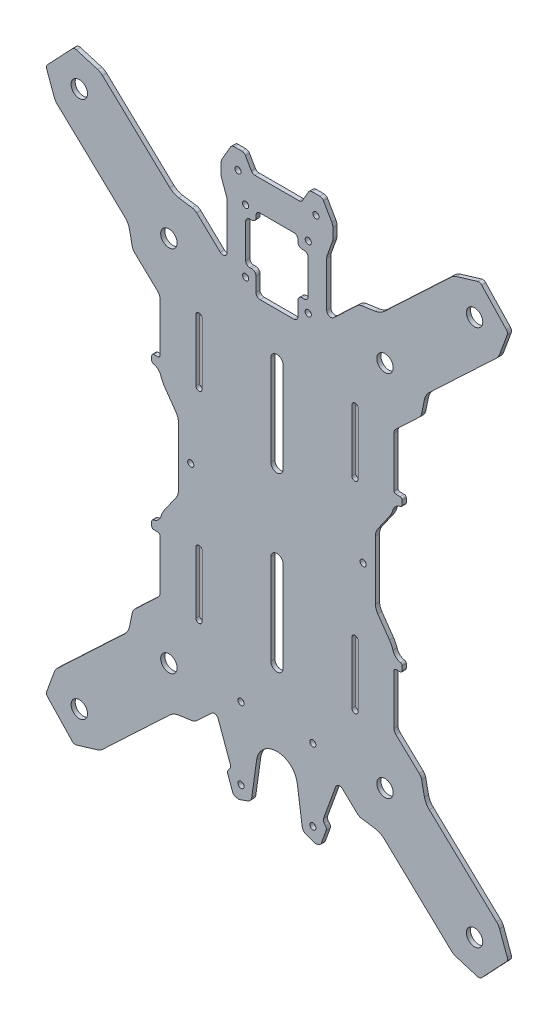
from build123d import *

# Parameters (mm, degrees)
MODEL_R             = 1.5
MODEL_R_2           = 4
BOSS_EXTRUDE1_DEPTH = 2


with BuildPart() as part:
    # Model → Boss-Extrude1 (new body)
    with BuildSketch(Plane.XY):
        with BuildLine():
            Line((200.412741898, 281.313149756), (207.019417582, 282.280309624))
            ThreePointArc((207.019417582, 282.280309624), (209.346062513, 282.995121659), (211.350075005, 284.376485771))
            Line((211.350075005, 284.376485771), (244.129053352, 315.296551711))
            ThreePointArc((244.129053352, 315.296551711), (245.241966673, 316.125703781), (246.515608428, 316.676980382))
            Line((246.515608428, 316.676980382), (256.822115777, 319.781518108))
            ThreePointArc((256.822115777, 319.781518108), (257.915045318, 319.798780278), (258.853822051, 319.238877422))
            Line((258.853822051, 319.238877422), (270.881078242, 306.488534933))
            ThreePointArc((270.881078242, 306.488534933), (271.385286838, 305.518706556), (271.304323373, 304.428643114))
            Line((271.304323373, 304.428643114), (267.604044674, 294.320716089))
            ThreePointArc((267.604044674, 294.320716089), (266.97943365, 293.081391094), (266.08679354, 292.018725103))
            Line((266.08679354, 292.018725103), (233.307822643, 261.098651713))
            ThreePointArc((233.307822643, 261.098651713), (231.811945064, 259.178604865), (230.962670444, 256.897604591))
            Line((230.962670444, 256.897604591), (229.611880181, 250.358572728))
            ThreePointArc((229.611880181, 250.358572728), (229.187245122, 249.218070958), (228.439307807, 248.258045441))
            Line((228.439307807, 248.258045441), (217.071655242, 237.535050637))
            ThreePointArc((217.071655242, 237.535050637), (216.375596078, 236.54111239), (216.130192427, 235.352756953))
            Line((216.130192427, 235.352756953), (216.130192427, 211.085992432))
            ThreePointArc((216.130192427, 211.085992432), (216.423085646, 210.378887349), (217.130190728, 210.085994131))
            Line((217.130190728, 210.085994131), (219.130191056, 210.085994131))
            ThreePointArc((219.130191056, 210.085994131), (219.837298547, 209.793102229), (220.130193083, 209.085995829))
            Line((220.130193083, 209.085995829), (220.130193083, 206.997061646))
            ThreePointArc((220.130193083, 206.997061646), (219.897158, 206.355372138), (219.306662985, 206.012755135))
            ThreePointArc((219.306662985, 206.012755135), (217.010488019, 204.889950302), (215.650192397, 202.725994205))
            ThreePointArc((215.650192397, 202.725994205), (214.949457219, 200.895279905), (213.960017113, 199.203076339))
            Line((213.960017113, 199.203076339), (208.215280471, 190.998742855))
            ThreePointArc((208.215280471, 190.998742855), (207.407891081, 189.361519051), (207.130192814, 187.557284287))
            Line((207.130192814, 187.557284287), (207.130192814, 158.688374361))
            ThreePointArc((207.130192814, 158.688374361), (207.407891081, 156.884139597), (208.215280471, 155.246915793))
            Line((208.215280471, 155.246915793), (213.960017113, 147.042582309))
            ThreePointArc((213.960017113, 147.042582309), (214.949457219, 145.350378743), (215.650192397, 143.519664444))
            ThreePointArc((215.650192397, 143.519664444), (217.010488019, 141.355708346), (219.306662985, 140.232903514))
            ThreePointArc((219.306662985, 140.232903514), (219.897158001, 139.89028651), (220.130193083, 139.248597002))
            Line((220.130193083, 139.248597002), (220.130193083, 137.159662819))
            ThreePointArc((220.130193083, 137.159662819), (219.837298547, 136.452556419), (219.130191056, 136.159664518))
            Line((219.130191056, 136.159664518), (217.130190728, 136.159664518))
            ThreePointArc((217.130190728, 136.159664518), (216.423085646, 135.866771299), (216.130192427, 135.159666216))
            Line((216.130192427, 135.159666216), (216.130192427, 110.892901695))
            ThreePointArc((216.130192427, 110.892901695), (216.375596078, 109.704546258), (217.071655242, 108.710608012))
            Line((217.071655242, 108.710608012), (228.439307807, 97.987613207))
            ThreePointArc((228.439307807, 97.987613207), (229.187245122, 97.02758769), (229.611880181, 95.887085921))
            Line((229.611880181, 95.887085921), (230.962670444, 89.348054058))
            ThreePointArc((230.962670444, 89.348054058), (231.811945064, 87.067053783), (233.307822643, 85.147006935))
            Line((233.307822643, 85.147006935), (266.08679354, 54.226933545))
            ThreePointArc((266.08679354, 54.226933545), (266.97943365, 53.164267554), (267.604044674, 51.924942559))
            Line((267.604044674, 51.924942559), (271.304323373, 41.817015535))
            ThreePointArc((271.304323373, 41.817015535), (271.385286838, 40.726952092), (270.881078242, 39.757123715))
            Line((270.881078242, 39.757123715), (258.853822051, 27.006781226))
            ThreePointArc((258.853822051, 27.006781226), (257.915045318, 26.44687837), (256.822115777, 26.464140541))
            Line((256.822115777, 26.464140541), (246.515608428, 29.568678266))
            ThreePointArc((246.515608428, 29.568678266), (245.241966673, 30.119954868), (244.129053352, 30.949106938))
            Line((244.129053352, 30.949106938), (211.350075005, 61.869172877))
            ThreePointArc((211.350075005, 61.869172877), (209.346062513, 63.25053699), (207.019417582, 63.965349025))
            Line((207.019417582, 63.965349025), (200.412741898, 64.932508892))
            ThreePointArc((200.412741898, 64.932508892), (199.24942012, 65.28991142), (198.247413186, 65.980589515))
            Line((198.247413186, 65.980589515), (191.012158094, 72.805537409))
            ThreePointArc((191.012158094, 72.805537409), (189.178482522, 73.296740969), (187.76041366, 72.034707791))
            Line((187.76041366, 72.034707791), (181.83126211, 55.744505054))
            ThreePointArc((181.83126211, 55.744505054), (181.741033127, 54.713169482), (182.178559748, 53.774891919))
            Line((182.178559748, 53.774891919), (182.735229878, 53.111477321))
            ThreePointArc((182.735229878, 53.111477321), (183.172757635, 52.173195972), (183.082525654, 51.141856736))
            Line((183.082525654, 51.141856736), (180.712941138, 44.631472355))
            ThreePointArc((180.712941138, 44.631472355), (180.11912963, 43.783427967), (179.180852173, 43.345904476))
            Line((179.180852173, 43.345904476), (177.86146052, 43.113252646))
            ThreePointArc((177.86146052, 43.113252646), (177.60065559, 43.101868291), (177.345790936, 43.158373362))
            Line((177.345790936, 43.158373362), (173.367758317, 44.606259591))
            ThreePointArc((173.367758317, 44.606259591), (172.062380787, 45.537377253), (171.42301522, 47.007820135))
            Line((171.42301522, 47.007820135), (169.03287269, 64.014560109))
            ThreePointArc((169.03287269, 64.014560109), (159.130192397, 72.622826292), (149.227512104, 64.014560109))
            Line((149.227512104, 64.014560109), (146.837369574, 47.007820135))
            ThreePointArc((146.837369574, 47.007820135), (146.198004008, 45.537377253), (144.892626477, 44.606259591))
            Line((144.892626477, 44.606259591), (140.914593859, 43.158373362))
            ThreePointArc((140.914593859, 43.158373362), (140.659729204, 43.101868291), (140.398924274, 43.113252646))
            Line((140.398924274, 43.113252646), (139.079532621, 43.345904476))
            ThreePointArc((139.079532621, 43.345904476), (138.141255164, 43.783427967), (137.547443656, 44.631472355))
            Line((137.547443656, 44.631472355), (135.177859141, 51.141856736))
            ThreePointArc((135.177859141, 51.141856736), (135.087627159, 52.173195972), (135.525154917, 53.111477321))
            Line((135.525154917, 53.111477321), (136.081825046, 53.774891919))
            ThreePointArc((136.081825046, 53.774891919), (136.519351668, 54.713169482), (136.429122685, 55.744505054))
            Line((136.429122685, 55.744505054), (130.499971135, 72.034707791))
            ThreePointArc((130.499971135, 72.034707791), (129.081902272, 73.296740969), (127.2482267, 72.805537409))
            Line((127.2482267, 72.805537409), (120.012971608, 65.980589515))
            ThreePointArc((120.012971608, 65.980589515), (119.010964675, 65.28991142), (117.847642897, 64.932508892))
            Line((117.847642897, 64.932508892), (111.240967212, 63.965349025))
            ThreePointArc((111.240967212, 63.965349025), (108.914322282, 63.25053699), (106.91030979, 61.869172877))
            Line((106.91030979, 61.869172877), (74.131331442, 30.949106938))
            ThreePointArc((74.131331442, 30.949106938), (73.018418122, 30.119954868), (71.744776366, 29.568678266))
            Line((71.744776366, 29.568678266), (61.438269017, 26.464140541))
            ThreePointArc((61.438269017, 26.464140541), (60.345339477, 26.44687837), (59.406562744, 27.006781226))
            Line((59.406562744, 27.006781226), (47.379306553, 39.757123715))
            ThreePointArc((47.379306553, 39.757123715), (46.875097957, 40.726952092), (46.956061421, 41.817015535))
            Line((46.956061421, 41.817015535), (50.65634012, 51.924942559))
            ThreePointArc((50.65634012, 51.924942559), (51.280951144, 53.164267554), (52.173591254, 54.226933545))
            Line((52.173591254, 54.226933545), (84.952562152, 85.147006935))
            ThreePointArc((84.952562152, 85.147006935), (86.44843973, 87.067053783), (87.297714351, 89.348054058))
            Line((87.297714351, 89.348054058), (88.648504613, 95.887085921))
            ThreePointArc((88.648504613, 95.887085921), (89.073139673, 97.02758769), (89.821076987, 97.987613207))
            Line((89.821076987, 97.987613207), (101.188729553, 108.710608012))
            ThreePointArc((101.188729553, 108.710608012), (101.884788716, 109.704546258), (102.130192367, 110.892901695))
            Line((102.130192367, 110.892901695), (102.130192367, 135.159666216))
            ThreePointArc((102.130192367, 135.159666216), (101.837299149, 135.866771299), (101.130194066, 136.159664518))
            Line((101.130194066, 136.159664518), (99.130193738, 136.159664518))
            ThreePointArc((99.130193738, 136.159664518), (98.423086248, 136.452556419), (98.130191712, 137.159662819))
            Line((98.130191712, 137.159662819), (98.130191712, 139.248597002))
            ThreePointArc((98.130191712, 139.248597002), (98.363226794, 139.89028651), (98.953721809, 140.232903514))
            ThreePointArc((98.953721809, 140.232903514), (101.249896776, 141.355708346), (102.610192397, 143.519664443))
            ThreePointArc((102.610192397, 143.519664443), (103.310927575, 145.350378743), (104.300367681, 147.042582309))
            Line((104.300367681, 147.042582309), (110.045104323, 155.246915793))
            ThreePointArc((110.045104323, 155.246915793), (110.852493714, 156.884139597), (111.13019198, 158.688374361))
            Line((111.13019198, 158.688374361), (111.13019198, 187.557284287))
            ThreePointArc((111.13019198, 187.557284287), (110.852493714, 189.361519051), (110.045104323, 190.998742855))
            Line((110.045104323, 190.998742855), (104.300367681, 199.203076339))
            ThreePointArc((104.300367681, 199.203076339), (103.310927575, 200.895279905), (102.610192397, 202.725994205))
            ThreePointArc((102.610192397, 202.725994205), (101.249896776, 204.889950302), (98.953721809, 206.012755135))
            ThreePointArc((98.953721809, 206.012755135), (98.363226794, 206.355372138), (98.130191712, 206.997061646))
            Line((98.130191712, 206.997061646), (98.130191712, 209.085995829))
            ThreePointArc((98.130191712, 209.085995829), (98.423086248, 209.793102229), (99.130193738, 210.085994131))
            Line((99.130193738, 210.085994131), (101.130194066, 210.085994131))
            ThreePointArc((101.130194066, 210.085994131), (101.837299149, 210.378887349), (102.130192367, 211.085992432))
            Line((102.130192367, 211.085992432), (102.130192367, 235.352756953))
            ThreePointArc((102.130192367, 235.352756953), (101.884788716, 236.54111239), (101.188729553, 237.535050637))
            Line((101.188729553, 237.535050637), (89.821076987, 248.258045441))
            ThreePointArc((89.821076987, 248.258045441), (89.073139673, 249.218070958), (88.648504613, 250.358572728))
            Line((88.648504613, 250.358572728), (87.297714351, 256.897604591))
            ThreePointArc((87.297714351, 256.897604591), (86.44843973, 259.178604865), (84.952562152, 261.098651713))
            Line((84.952562152, 261.098651713), (52.173591254, 292.018725103))
            ThreePointArc((52.173591254, 292.018725103), (51.280951144, 293.081391094), (50.65634012, 294.320716089))
            Line((50.65634012, 294.320716089), (46.956061421, 304.428643114))
            ThreePointArc((46.956061421, 304.428643114), (46.875097957, 305.518706556), (47.379306553, 306.488534933))
            Line((47.379306553, 306.488534933), (59.406562744, 319.238877422))
            ThreePointArc((59.406562744, 319.238877422), (60.345339477, 319.798780278), (61.438269017, 319.781518108))
            Line((61.438269017, 319.781518108), (71.744776366, 316.676980382))
            ThreePointArc((71.744776366, 316.676980382), (73.018418122, 316.125703781), (74.131331442, 315.296551711))
            Line((74.131331442, 315.296551711), (106.91030979, 284.376485771))
            ThreePointArc((106.91030979, 284.376485771), (108.914322282, 282.995121659), (111.240967212, 282.280309624))
            Line((111.240967212, 282.280309624), (117.847642897, 281.313149756))
            ThreePointArc((117.847642897, 281.313149756), (119.010964675, 280.955747228), (120.012971608, 280.265069133))
            Line((120.012971608, 280.265069133), (131.507833524, 269.422082728))
            ThreePointArc((131.507833524, 269.422082728), (133.67243115, 269.040550313), (134.880191682, 270.876950151))
            Line((134.880191682, 270.876950151), (134.880191682, 292.844689018))
            ThreePointArc((134.880191682, 292.844689018), (134.819423011, 293.539282981), (134.638962371, 294.212772077))
            Line((134.638962371, 294.212772077), (132.121422363, 301.129660136))
            ThreePointArc((132.121422363, 301.129660136), (131.94096237, 301.803145563), (131.880193053, 302.497735745))
            Line((131.880193053, 302.497735745), (131.880193053, 307.258924967))
            ThreePointArc((131.880193053, 307.258924967), (132.016490923, 308.294195505), (132.416090964, 309.258914119))
            Line((132.416090964, 309.258914119), (136.498994229, 316.330707199))
            ThreePointArc((136.498994229, 316.330707199), (137.231044932, 317.062759296), (138.231045602, 317.330709225))
            Line((138.231045602, 317.330709225), (142.029338552, 317.330709225))
            ThreePointArc((142.029338552, 317.330709225), (143.029339222, 317.062759296), (143.761389924, 316.330707199))
            Line((143.761389924, 316.330707199), (146.648141591, 311.330711967))
            ThreePointArc((146.648141591, 311.330711967), (147.38019189, 310.598660102), (148.380192032, 310.33070994))
            Line((148.380192032, 310.33070994), (169.880192762, 310.33070994))
            ThreePointArc((169.880192762, 310.33070994), (170.880192904, 310.598660102), (171.612243203, 311.330711967))
            Line((171.612243203, 311.330711967), (174.49899487, 316.330707199))
            ThreePointArc((174.49899487, 316.330707199), (175.231045573, 317.062759296), (176.231046243, 317.330709225))
            Line((176.231046243, 317.330709225), (180.029339193, 317.330709225))
            ThreePointArc((180.029339193, 317.330709225), (181.029339863, 317.062759296), (181.761390565, 316.330707199))
            Line((181.761390565, 316.330707199), (185.844293831, 309.258914119))
            ThreePointArc((185.844293831, 309.258914119), (186.243893872, 308.294195505), (186.380191742, 307.258924967))
            Line((186.380191742, 307.258924967), (186.380191742, 302.497735745))
            ThreePointArc((186.380191742, 302.497735745), (186.319422424, 301.803145563), (186.138962431, 301.129660136))
            Line((186.138962431, 301.129660136), (183.621422423, 294.212772077))
            ThreePointArc((183.621422423, 294.212772077), (183.440961783, 293.539282981), (183.380193112, 292.844689018))
            Line((183.380193112, 292.844689018), (183.380193112, 270.876950151))
            ThreePointArc((183.380193112, 270.876950151), (184.587953644, 269.040550313), (186.752551271, 269.422082728))
            Line((186.752551271, 269.422082728), (198.247413186, 280.265069133))
            ThreePointArc((198.247413186, 280.265069133), (199.24942012, 280.955747228), (200.412741898, 281.313149756))
        make_face()
        with Locations((174.380192397, 265.122829324)):
            Circle(MODEL_R, mode=Mode.SUBTRACT)
        with Locations((143.880192397, 295.622829324)):
            Circle(MODEL_R, mode=Mode.SUBTRACT)
        with Locations((176.630192397, 84.767778966)):
            Circle(MODEL_R, mode=Mode.SUBTRACT)
        with Locations((141.630192397, 49.767778966)):
            Circle(MODEL_R, mode=Mode.SUBTRACT)
        with Locations((106.49549278, 262.77260343)):
            Circle(MODEL_R_2, mode=Mode.SUBTRACT)
        with Locations((62.849554611, 303.943370745)):
            Circle(MODEL_R_2, mode=Mode.SUBTRACT)
        with Locations((106.49549278, 83.473055219)):
            Circle(MODEL_R_2, mode=Mode.SUBTRACT)
        with Locations((62.849554611, 42.302287903)):
            Circle(MODEL_R_2, mode=Mode.SUBTRACT)
        with Locations((255.410830183, 42.302287903)):
            Circle(MODEL_R_2, mode=Mode.SUBTRACT)
        with Locations((211.764892015, 83.473055219)):
            Circle(MODEL_R_2, mode=Mode.SUBTRACT)
        with Locations((255.410830183, 303.943370745)):
            Circle(MODEL_R_2, mode=Mode.SUBTRACT)
        with Locations((211.764892015, 262.77260343)):
            Circle(MODEL_R_2, mode=Mode.SUBTRACT)
        with Locations((176.630192397, 49.767778966)):
            Circle(MODEL_R, mode=Mode.SUBTRACT)
        with Locations((141.630192397, 84.767778966)):
            Circle(MODEL_R, mode=Mode.SUBTRACT)
        with Locations((174.380192397, 295.622829324)):
            Circle(MODEL_R, mode=Mode.SUBTRACT)
        with Locations((143.880192397, 265.122829324)):
            Circle(MODEL_R, mode=Mode.SUBTRACT)
        with Locations((201.130192397, 173.122829324)):
            Circle(MODEL_R, mode=Mode.SUBTRACT)
        with Locations((117.130192397, 173.122829324)):
            Circle(MODEL_R, mode=Mode.SUBTRACT)
        with Locations((178.130192397, 308.330714568)):
            Circle(MODEL_R, mode=Mode.SUBTRACT)
        with Locations((140.130192397, 308.330714568)):
            Circle(MODEL_R, mode=Mode.SUBTRACT)
        with BuildLine():
            Line((119.630190579, 109.122826284), (119.630190579, 139.122827476))
            ThreePointArc((119.630190579, 139.122827476), (121.130191756, 140.622828654), (122.630192934, 139.122827476))
            Line((122.630192934, 139.122827476), (122.630192934, 109.122826284))
            ThreePointArc((122.630192934, 109.122826284), (121.130191756, 107.622825107), (119.630190579, 109.122826284))
        make_face(mode=Mode.SUBTRACT)
        with BuildLine():
            Line((198.630194215, 237.122832364), (198.630194215, 207.122831172))
            ThreePointArc((198.630194215, 207.122831172), (197.130193038, 205.622829995), (195.630191861, 207.122831172))
            Line((195.630191861, 207.122831172), (195.630191861, 237.122832364))
            ThreePointArc((195.630191861, 237.122832364), (197.130193038, 238.622833541), (198.630194215, 237.122832364))
        make_face(mode=Mode.SUBTRACT)
        with BuildLine():
            Line((146.880192718, 270.122832185), (145.880192554, 270.122832185))
            ThreePointArc((145.880192554, 270.122832185), (144.465979981, 270.708617306), (143.880192226, 272.122828788))
            Line((143.880192226, 272.122828788), (143.880192226, 288.622832424))
            ThreePointArc((143.880192226, 288.622832424), (144.465979981, 290.037043906), (145.880192554, 290.622829026))
            Line((145.880192554, 290.622829026), (146.880192718, 290.622829026))
            ThreePointArc((146.880192718, 290.622829026), (148.294404689, 291.208614476), (148.880192114, 292.622825629))
            Line((148.880192114, 292.622825629), (148.880192114, 293.622827655))
            ThreePointArc((148.880192114, 293.622827655), (149.465977235, 295.037043954), (150.880192442, 295.622831708))
            Line((150.880192442, 295.622831708), (167.380192352, 295.622831708))
            ThreePointArc((167.380192352, 295.622831708), (168.79440756, 295.037043954), (169.38019268, 293.622827655))
            Line((169.38019268, 293.622827655), (169.38019268, 292.622825629))
            ThreePointArc((169.38019268, 292.622825629), (169.965980106, 291.208614476), (171.380192077, 290.622829026))
            Line((171.380192077, 290.622829026), (172.380192241, 290.622829026))
            ThreePointArc((172.380192241, 290.622829026), (173.794404814, 290.037043906), (174.380192569, 288.622832424))
            Line((174.380192569, 288.622832424), (174.380192569, 272.122828788))
            ThreePointArc((174.380192569, 272.122828788), (173.794404814, 270.708617306), (172.380192241, 270.122832185))
            Line((172.380192241, 270.122832185), (171.380192077, 270.122832185))
            ThreePointArc((171.380192077, 270.122832185), (169.965977472, 269.537044101), (169.38019268, 268.122828132))
            Line((169.38019268, 268.122828132), (169.38019268, 261.122828847))
            ThreePointArc((169.38019268, 261.122828847), (168.794404926, 259.708617365), (167.380192352, 259.122832245))
            Line((167.380192352, 259.122832245), (150.880192442, 259.122832245))
            ThreePointArc((150.880192442, 259.122832245), (149.465979869, 259.708617365), (148.880192114, 261.122828847))
            Line((148.880192114, 261.122828847), (148.880192114, 268.122828132))
            ThreePointArc((148.880192114, 268.122828132), (148.294407323, 269.537044101), (146.880192718, 270.122832185))
        make_face(mode=Mode.SUBTRACT)
        with BuildLine():
            Line((162.130192423, 237.122832364), (162.130192423, 193.122828877))
            ThreePointArc((162.130192423, 193.122828877), (159.130192397, 190.122828851), (156.130192371, 193.122828877))
            Line((156.130192371, 193.122828877), (156.130192371, 237.122832364))
            ThreePointArc((156.130192371, 237.122832364), (159.130192397, 240.12283239), (162.130192423, 237.122832364))
        make_face(mode=Mode.SUBTRACT)
        with BuildLine():
            Line((156.130192371, 109.122826284), (156.130192371, 153.122829771))
            ThreePointArc((156.130192371, 153.122829771), (159.130192397, 156.122829797), (162.130192423, 153.122829771))
            Line((162.130192423, 153.122829771), (162.130192423, 109.122826284))
            ThreePointArc((162.130192423, 109.122826284), (159.130192397, 106.122826258), (156.130192371, 109.122826284))
        make_face(mode=Mode.SUBTRACT)
        with BuildLine():
            Line((122.630192934, 237.122832364), (122.630192934, 207.122831172))
            ThreePointArc((122.630192934, 207.122831172), (121.130191756, 205.622829995), (119.630190579, 207.122831172))
            Line((119.630190579, 207.122831172), (119.630190579, 237.122832364))
            ThreePointArc((119.630190579, 237.122832364), (121.130191756, 238.622833541), (122.630192934, 237.122832364))
        make_face(mode=Mode.SUBTRACT)
        with BuildLine():
            Line((195.630191861, 109.122826284), (195.630191861, 139.122827476))
            ThreePointArc((195.630191861, 139.122827476), (197.130193038, 140.622828654), (198.630194215, 139.122827476))
            Line((198.630194215, 139.122827476), (198.630194215, 109.122826284))
            ThreePointArc((198.630194215, 109.122826284), (197.130193038, 107.622825107), (195.630191861, 109.122826284))
        make_face(mode=Mode.SUBTRACT)
    extrude(amount=BOSS_EXTRUDE1_DEPTH)


solid = part.part
